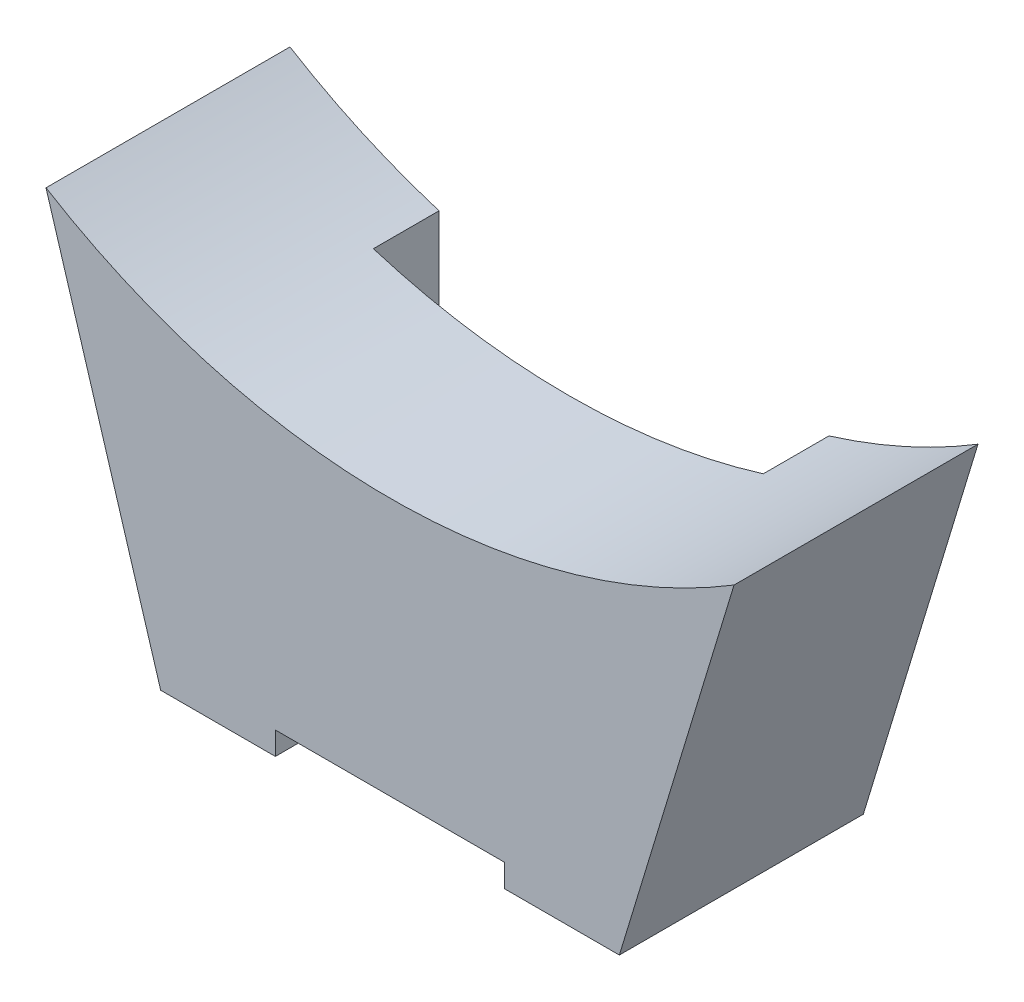
from build123d import *

# Parameters (mm, degrees)
BOSS_EXTRU_1_DEPTH      = 18.275
ESQUISSE2_W             = 40
ESQUISSE2_H             = 22
BOSS_EXTRU_2_DEPTH      = 3
ESQUISSE3_W             = 40
ESQUISSE3_H             = 2
BOSS_EXTRU_3_DEPTH      = 2
ESQUISSE4_W             = 20
ESQUISSE4_H             = 2
ENL_V_MAT_EXTRU_2_DEPTH = 22.275
ENL_V_START             = -7.775
ESQUISSE5_W             = 31.2
ESQUISSE5_H             = 5
ENL_V_MAT_EXTRU_3_DEPTH = 7.775
ESQUISSE6_W             = 34
ESQUISSE6_H             = 5.725
ENL_V_MAT_EXTRU_4_DEPTH = 12.5
BOSS_EXTRU_4_DEPTH      = 21.275
ESQUISSE8_W             = 34
ESQUISSE8_H             = 5.725
ENL_V_MAT_EXTRU_5_DEPTH = 11.946457824


with BuildPart() as part:
    # Esquisse1 → Boss.-Extru.1 (new body)
    with BuildSketch(Plane.XY):
        Polygon((-15.6, -80), (-20, -80), (-20, -60), (20, -60), (20, -80), (15.6, -80), (15.6, -76.5), (8.8, -76.5), (8.8, -71.5), (-8.8, -71.5), (-8.8, -76.5), (-15.6, -76.5), align=None)
    extrude(amount=BOSS_EXTRU_1_DEPTH)

    # Esquisse2 → Boss.-Extru.2 (add)
    with BuildSketch(Plane.XY.offset(18.275)):
        with Locations((0, -71)):
            Rectangle(ESQUISSE2_W, ESQUISSE2_H)
    extrude(amount=BOSS_EXTRU_2_DEPTH)

    # Esquisse3 → Boss.-Extru.3 (add)
    with BuildSketch(Plane(origin=(0, 0, 18.275), x_dir=(-1, 0, 0), z_dir=(0, 0, -1))):
        with Locations((0, -81)):
            Rectangle(ESQUISSE3_W, ESQUISSE3_H)
    extrude(amount=BOSS_EXTRU_3_DEPTH)

    # Esquisse4 → Enlèv. mat.-Extru.2 (cut, through all)
    with BuildSketch(Plane.XY.offset(21.275)):
        with Locations((0, -81)):
            Rectangle(ESQUISSE4_W, ESQUISSE4_H)
    extrude(amount=-ENL_V_MAT_EXTRU_2_DEPTH, mode=Mode.SUBTRACT)

    # Esquisse5 → Enlèv. mat.-Extru.3 (cut)
    with BuildSketch(Plane(origin=(0, 0, 0), x_dir=(-1, 0, 0), z_dir=(0, 0, -1)).offset(ENL_V_START)):
        with Locations((0, -74)):
            Rectangle(ESQUISSE5_W, ESQUISSE5_H)
    extrude(amount=ENL_V_MAT_EXTRU_3_DEPTH, mode=Mode.SUBTRACT)

    # Esquisse6 → Enlèv. mat.-Extru.4 (cut, through all)
    with BuildSketch(Plane.XZ.offset(71.5)):
        with Locations((0, 2.8625)):
            Rectangle(ESQUISSE6_W, ESQUISSE6_H)
    extrude(amount=-ENL_V_MAT_EXTRU_4_DEPTH, mode=Mode.SUBTRACT)

    # Esquisse7 → Boss.-Extru.4 (add)
    with BuildSketch(Plane.XY.offset(21.275)):
        with BuildLine():
            Line((-30, -49.053542176), (-20, -82))
            Line((-20, -82), (-18, -82))
            Line((-18, -82), (-18, -60))
            Line((-18, -60), (18, -60))
            Line((18, -60), (18, -82))
            Line((18, -82), (20, -82))
            Line((20, -82), (30, -49.053542176))
            ThreePointArc((30, -49.053542176), (0, -57.5), (-30, -49.053542176))
        make_face()
    extrude(amount=-BOSS_EXTRU_4_DEPTH)

    # Esquisse8 → Enlèv. mat.-Extru.5 (cut, through all)
    with BuildSketch(Plane.XZ.offset(60)):
        with Locations((0, 2.8625)):
            Rectangle(ESQUISSE8_W, ESQUISSE8_H)
    extrude(amount=-ENL_V_MAT_EXTRU_5_DEPTH, mode=Mode.SUBTRACT)


solid = part.part
